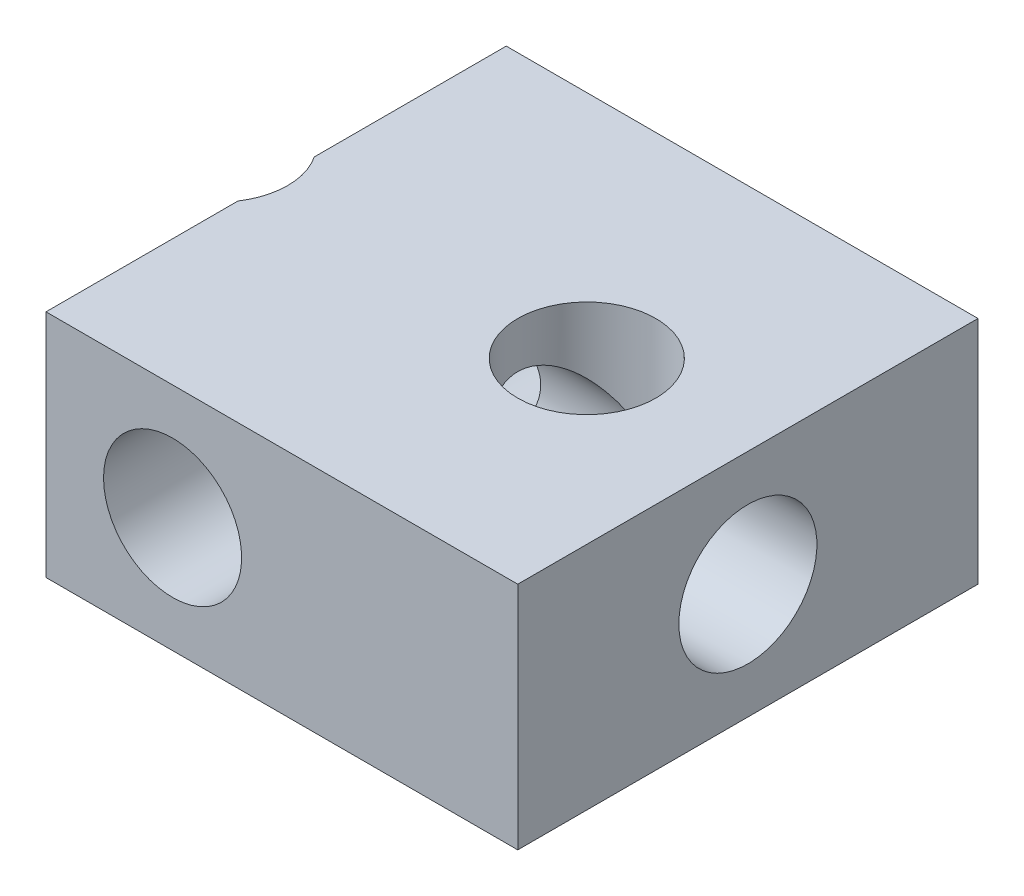
from build123d import *

# Parameters (mm, degrees)
SKETCH1_W               = 15
SKETCH1_H               = 10
SKETCH1_R               = 1.5
BOSS_EXTRUDE1_DEPTH     = 5
SKETCH2_R               = 1.5
CUT_EXTRUDE1_DEPTH      = 1
CUT_EXTRUDE1_DEPTH_BACK = 16
SKETCH3_R               = 1.5
CUT_EXTRUDE2_DEPTH      = 1
CUT_EXTRUDE2_DEPTH_BACK = 11
SKETCH4_W               = 10
SKETCH4_H               = 5
CUT_EXTRUDE3_DEPTH      = 4.75


with BuildPart() as part:
    # Sketch1 → Boss-Extrude1 (new body)
    with BuildSketch(Plane(origin=(0, 0, 0), x_dir=(1, 0, 0), z_dir=(0, 1, 0))):
        Rectangle(SKETCH1_W, SKETCH1_H)
        with Locations((4, 0)):
            Circle(SKETCH1_R, mode=Mode.SUBTRACT)
        with Locations((-4, 0)):
            Circle(SKETCH1_R, mode=Mode.SUBTRACT)
    extrude(amount=BOSS_EXTRUDE1_DEPTH)

    # Sketch2 → Cut-Extrude1 (cut, two sides)
    with BuildSketch(Plane.ZY.offset(7.5)) as cut_extrude1_sk:
        with Locations((0, 2.5)):
            Circle(SKETCH2_R)
    extrude(amount=CUT_EXTRUDE1_DEPTH, mode=Mode.SUBTRACT)
    extrude(cut_extrude1_sk.sketch, amount=-CUT_EXTRUDE1_DEPTH_BACK, mode=Mode.SUBTRACT)

    # Sketch3 → Cut-Extrude2 (cut, two sides)
    with BuildSketch(Plane(origin=(0, 0, -5), x_dir=(-1, 0, 0), z_dir=(0, 0, -1))) as cut_extrude2_sk:
        with Locations((0, 2.5)):
            Circle(SKETCH3_R)
    extrude(amount=CUT_EXTRUDE2_DEPTH, mode=Mode.SUBTRACT)
    extrude(cut_extrude2_sk.sketch, amount=-CUT_EXTRUDE2_DEPTH_BACK, mode=Mode.SUBTRACT)

    # Sketch4 → Cut-Extrude3 (cut)
    with BuildSketch(Plane.ZY.offset(7.5)):
        with Locations((0, 2.5)):
            Rectangle(SKETCH4_W, SKETCH4_H)
    extrude(amount=-CUT_EXTRUDE3_DEPTH, mode=Mode.SUBTRACT)


solid = part.part
